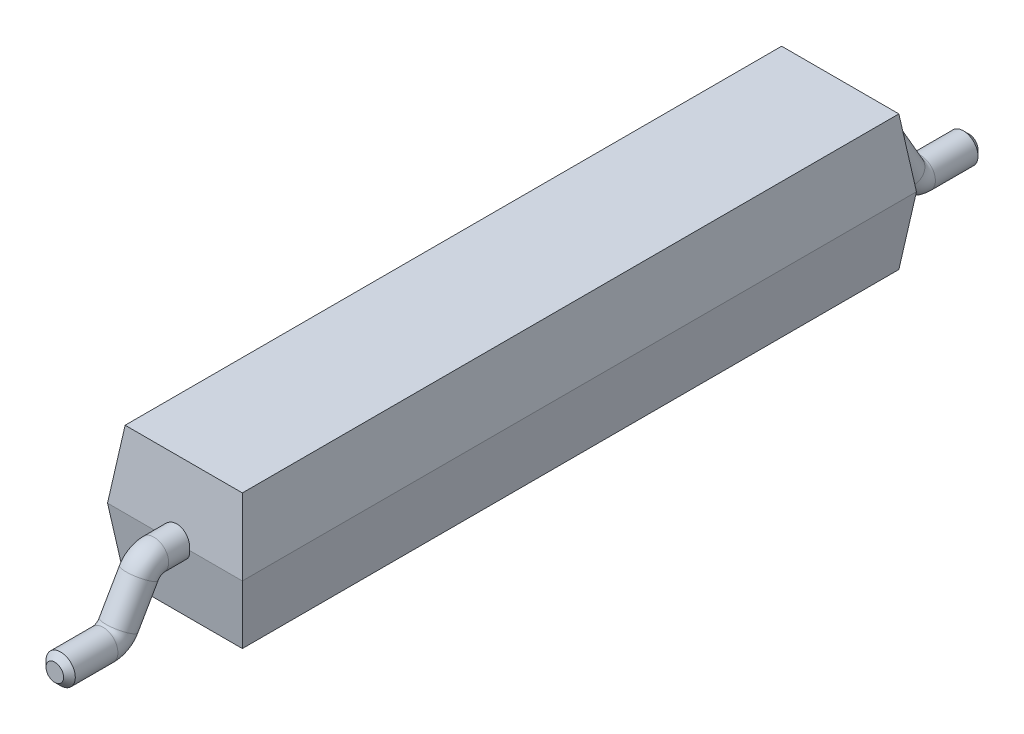
from build123d import *

# Parameters (mm, degrees)
BOSS_EXTRUDE1_DEPTH     = 5.75
CUT_EXTRUDE1_DEPTH      = 7.298809411
CUT_EXTRUDE1_DEPTH_BACK = 11
SKETCH4_R               = 0.25
CHAMFER1_SIZE           = 0.1


with BuildPart() as part:
    # Sketch1 → Boss-Extrude1 (new, symmetric)
    with BuildSketch(Plane.XY):
        Polygon((-1, 0), (1, 0), (1.15, 1.15), (1, 2.3), (-1, 2.3), (-1.15, 1.15), align=None)
    extrude(amount=BOSS_EXTRUDE1_DEPTH, both=True)

    # Sketch2 → Cut-Extrude1 (cut, two sides: drawn at the far end of the back side and taken through both)
    with BuildSketch(Plane(origin=(0, 0, 0), x_dir=(0, 0, -1), z_dir=(1, 0, 0)).offset(-CUT_EXTRUDE1_DEPTH_BACK)):
        Polygon((5.75, 1.15), (5.6, 2.3), (6.6, 2.3), (6.6, 0), (5.6, 0), align=None)
        Polygon((-5.6, 0), (-5.75, 1.15), (-5.6, 2.3), (-6.6, 2.3), (-6.6, 0), align=None)
    extrude(amount=CUT_EXTRUDE1_DEPTH + CUT_EXTRUDE1_DEPTH_BACK, mode=Mode.SUBTRACT)

    # Sweep1: sweep along a path in Sketch5
    with BuildLine(Plane(origin=(0, 0, 0), x_dir=(0, 0, -1), z_dir=(1, 0, 0))) as sweep1_path:
        Line((-5, 1.15), (-6.107179677, 1.15))
        ThreePointArc((-6.107179677, 1.15), (-6.257179677, 1.109807621), (-6.366987298, 1))
        Line((-6.366987298, 1), (-6.71339746, 0.4))
        ThreePointArc((-6.71339746, 0.4), (-6.823205081, 0.290192379), (-6.973205081, 0.25))
        Line((-6.973205081, 0.25), (-7.8, 0.25))
    # Sketch4 → Sweep1 (sweep)
    with BuildSketch(Plane.XY.offset(5)):
        with Locations((0, 1.15)):
            Circle(SKETCH4_R)
    sweep1 = sweep(path=sweep1_path.line)

    # Mirror1: Sweep1 across plane
    add(sweep1.mirror(Plane.XY))

    # Chamfer1
    chamfer1_edges = [part.edges().sort_by_distance(p)[0] for p in [
        (-0.25, 0.25, -7.8),
        (-0.25, 0.25, 7.8),
    ]]
    chamfer(chamfer1_edges, length=CHAMFER1_SIZE)


solid = part.part
